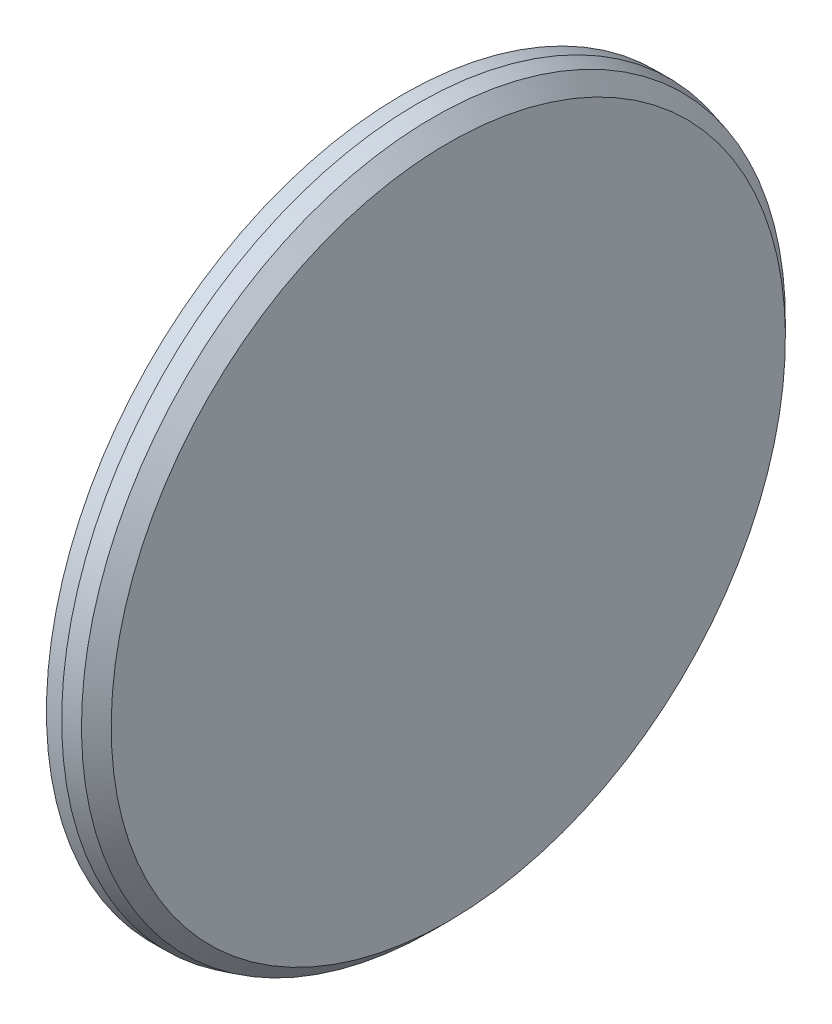
from build123d import *

# Parameters (mm, degrees)
BOSS_EXTRUDE2_DEPTH = 20


with BuildPart() as part:
    # Sketch1 → Revolve2 (revolve)
    with BuildSketch(Plane.XY, mode=Mode.PRIVATE) as revolve2_sk:
        Polygon((-40, 0), (40, 0), (40, 100), (40, 442.5), (20.490381057, 462.009618943), (0, 467.5), (-20, 467.5), (-20, 422.5), (10, 422.5), (10, 100), (-40, 100), align=None)
    revolve(revolve2_sk.sketch.rotate(Axis((-40, 0, 0), (1, 0, 0)), 180), axis=Axis((-40, 0, 0), (1, 0, 0)))

    # Sketch2 → Boss-Extrude2 (add)
    with BuildSketch(Plane.ZY.offset(-10)):
        with BuildLine():
            ThreePointArc((30.727272727, 421.381163213), (-31.600916525, 421.316546168), (-93.24137931, 412.08287417))
            ThreePointArc((-93.24137931, 412.08287417), (-42.546580654, 400.436970696), (-20, 353.562229318))
            Line((-20, 353.562229318), (-20, 105.830052443))
            ThreePointArc((-20, 105.830052443), (-22.022759648, 99.799825551), (-27.272727273, 96.209138584))
            ThreePointArc((-27.272727273, 96.209138584), (0, 100), (27.272727273, 96.209138584))
            ThreePointArc((27.272727273, 96.209138584), (22.022759648, 99.799825551), (20, 105.830052443))
            Line((20, 105.830052443), (20, 411.407644557))
            ThreePointArc((20, 411.407644557), (23.19091516, 418.73132967), (30.727272727, 421.381163213))
        make_face()
        with BuildLine():
            ThreePointArc((294.397047194, 303.045588326), (246.609349131, 343.059876583), (193.454725191, 375.608199193))
            ThreePointArc((193.454725191, 375.608199193), (224.80335154, 334.1009311), (211.944531396, 283.700133259))
            Line((211.944531396, 283.700133259), (52.70535758, 93.926275782))
            ThreePointArc((52.70535758, 93.926275782), (47.279678663, 90.60705882), (40.949921045, 91.231047163))
            ThreePointArc((40.949921045, 91.231047163), (64.278760969, 76.604444312), (82.734163396, 56.169904816))
            ThreePointArc((82.734163396, 56.169904816), (81.020503963, 62.295144755), (83.347135305, 68.214771395))
            Line((83.347135305, 68.214771395), (279.768625314, 302.300787776))
            ThreePointArc((279.768625314, 302.300787776), (286.920582188, 305.859975332), (294.397047194, 303.045588326))
        make_face()
        with BuildLine():
            ThreePointArc((-249.126847589, 328.012292163), (-251.390038811, 335.673641176), (-247.320134144, 342.547808703))
            ThreePointArc((-247.320134144, 342.547808703), (-295.024762134, 302.434521389), (-336.30880617, 255.739392532))
            ThreePointArc((-336.30880617, 255.739392532), (-289.988494908, 279.404101342), (-242.586309121, 257.988628872))
            Line((-242.586309121, 257.988628872), (-83.347135305, 68.214771395))
            ThreePointArc((-83.347135305, 68.214771395), (-81.020503963, 62.295144755), (-82.734163396, 56.169904816))
            ThreePointArc((-82.734163396, 56.169904816), (-64.278760969, 76.604444312), (-40.949921045, 91.231047163))
            ThreePointArc((-40.949921045, 91.231047163), (-47.279678663, 90.60705882), (-52.70535758, 93.926275782))
            Line((-52.70535758, 93.926275782), (-249.126847589, 328.012292163))
        make_face()
        with BuildLine():
            ThreePointArc((-17.402157289, -106.288122204), (-13.438925908, -101.313387037), (-7.277482801, -99.73483967))
            ThreePointArc((-7.277482801, -99.73483967), (-34.202014333, -93.969262079), (-58.533443935, -81.079195489))
            ThreePointArc((-58.533443935, -81.079195489), (-54.828175369, -86.248932215), (-54.98986212, -92.607316471))
            Line((-54.98986212, -92.607316471), (-159.503553972, -379.756324859))
            ThreePointArc((-159.503553972, -379.756324859), (-165.006881234, -385.546980456), (-172.995037276, -385.459423387))
            ThreePointArc((-172.995037276, -385.459423387), (-114.403597437, -406.716199448), (-53.322407596, -419.121665926))
            ThreePointArc((-53.322407596, -419.121665926), (-96.97680223, -390.839454066), (-102.13155193, -339.080220745))
            Line((-102.13155193, -339.080220745), (-17.402157289, -106.288122204))
        make_face()
        with BuildLine():
            ThreePointArc((58.533443935, -81.079195489), (34.202014333, -93.969262079), (7.277482801, -99.73483967))
            ThreePointArc((7.277482801, -99.73483967), (13.438925908, -101.313387037), (17.402157289, -106.288122204))
            Line((17.402157289, -106.288122204), (121.915849141, -393.437130592))
            ThreePointArc((121.915849141, -393.437130592), (121.422217544, -401.41050071), (115.246654398, -406.478115832))
            ThreePointArc((115.246654398, -406.478115832), (173.793893575, -385.09989945), (228.558879776, -355.340806094))
            ThreePointArc((228.558879776, -355.340806094), (176.938217991, -361.73587884), (139.719256761, -325.399415012))
            Line((139.719256761, -325.399415012), (54.98986212, -92.607316471))
            ThreePointArc((54.98986212, -92.607316471), (54.828175369, -86.248932215), (58.533443935, -81.079195489))
        make_face()
        with BuildLine():
            ThreePointArc((420.315171419, 42.911614684), (409.428359571, 104.28167806), (389.631213766, 163.382273394))
            ThreePointArc((389.631213766, 163.382273394), (386.965297138, 111.435352724), (344.717861051, 81.091591873))
            Line((344.717861051, 81.091591873), (100.749292594, 38.073350809))
            ThreePointArc((100.749292594, 38.073350809), (94.459429872, 39.018242282), (90.011646197, 43.564934854))
            ThreePointArc((90.011646197, 43.564934854), (98.480775301, 17.364817767), (99.483364979, -10.151851674))
            ThreePointArc((99.483364979, -10.151851674), (102.107854032, -4.358126605), (107.6952197, -1.318959311))
            Line((107.6952197, -1.318959311), (408.630401562, 51.744032695))
            ThreePointArc((408.630401562, 51.744032695), (416.396920044, 49.873339281), (420.315171419, 42.911614684))
        make_face()
        with BuildLine():
            ThreePointArc((-401.684474455, 91.136342816), (-408.342799732, 95.550525378), (-409.643701592, 103.432527506))
            ThreePointArc((-409.643701592, 103.432527506), (-420.403242706, 42.040022866), (-422.013604967, -20.267393099))
            ThreePointArc((-422.013604967, -20.267393099), (-401.741569531, 27.634947739), (-351.663788158, 41.699281753))
            Line((-351.663788158, 41.699281753), (-107.6952197, -1.318959311))
            ThreePointArc((-107.6952197, -1.318959311), (-102.107854032, -4.358126605), (-99.483364979, -10.151851674))
            ThreePointArc((-99.483364979, -10.151851674), (-98.480775301, 17.364817767), (-90.011646197, 43.564934854))
            ThreePointArc((-90.011646197, 43.564934854), (-94.459429872, 39.018242282), (-100.749292594, 38.073350809))
            Line((-100.749292594, 38.073350809), (-401.684474455, 91.136342816))
        make_face()
        with BuildLine():
            ThreePointArc((-81.651513899, -70.235534297), (-75.417804397, -68.972182092), (-69.683194454, -71.723443941))
            ThreePointArc((-69.683194454, -71.723443941), (-86.602540378, -50), (-96.955921726, -24.485694643))
            ThreePointArc((-96.955921726, -24.485694643), (-97.440564044, -30.827643459), (-101.651513899, -35.594518146))
            Line((-101.651513899, -35.594518146), (-366.289471498, -188.383314203))
            ThreePointArc((-366.289471498, -188.383314203), (-374.227426435, -189.28174317), (-380.290428382, -184.079982836))
            ThreePointArc((-380.290428382, -184.079982836), (-349.070373753, -238.025469578), (-310.253547841, -286.790840252))
            ThreePointArc((-310.253547841, -286.790840252), (-325.51529891, -237.064905039), (-296.193872408, -194.101622734))
            Line((-296.193872408, -194.101622734), (-81.651513899, -70.235534297))
        make_face()
        with BuildLine():
            ThreePointArc((96.955921726, -24.485694643), (86.602540378, -50), (69.683194454, -71.723443941))
            ThreePointArc((69.683194454, -71.723443941), (75.417804397, -68.972182092), (81.651513899, -70.235534297))
            Line((81.651513899, -70.235534297), (346.289471498, -223.024330354))
            ThreePointArc((346.289471498, -223.024330354), (351.036511275, -229.4495865), (349.563155655, -237.301180377))
            ThreePointArc((349.563155655, -237.301180377), (380.671290279, -183.29107659), (403.494927151, -125.292033918))
            ThreePointArc((403.494927151, -125.292033918), (368.061879564, -163.372065657), (316.193872408, -159.460606583))
            Line((316.193872408, -159.460606583), (101.651513899, -35.594518146))
            ThreePointArc((101.651513899, -35.594518146), (97.440564044, -30.827643459), (96.955921726, -24.485694643))
        make_face()
    extrude(amount=BOSS_EXTRUDE2_DEPTH)


solid = part.part
